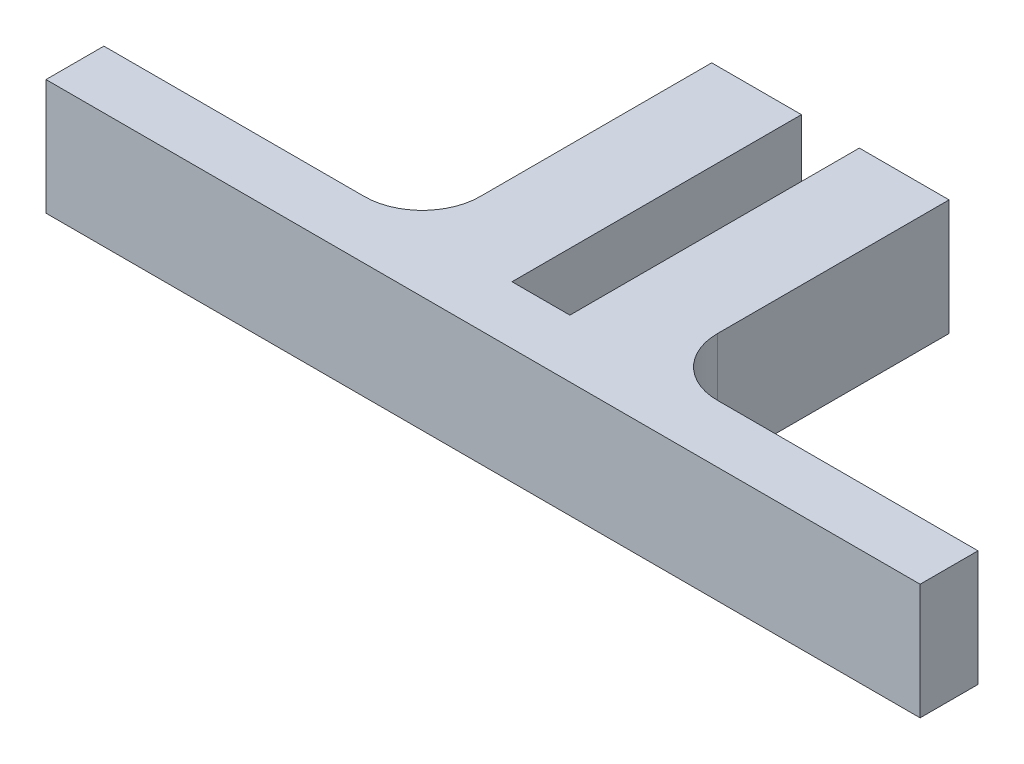
from build123d import *

# Parameters (mm, degrees)
BOSS_EXTRUDE2_DEPTH = 20
SKETCH4_W           = 10
SKETCH4_H           = 20
CUT_EXTRUDE1_DEPTH  = 50


with BuildPart() as part:
    # Sketch1 → Boss-Extrude2 (new body)
    with BuildSketch(Plane(origin=(0, 0, 0), x_dir=(1, 0, 0), z_dir=(0, 1, 0))):
        with BuildLine():
            Line((-80.69665409, 52.02034588), (-35.69665409, 52.02034588))
            ThreePointArc((-35.69665409, 52.02034588), (-28.625586278, 54.949278068), (-25.69665409, 62.02034588))
            Line((-25.69665409, 62.02034588), (-25.69665409, 102.02034588))
            Line((-25.69665409, 102.02034588), (15.30334591, 102.02034588))
            Line((15.30334591, 102.02034588), (15.30334591, 62.02034588))
            ThreePointArc((15.30334591, 62.02034588), (18.232278099, 54.949278068), (25.30334591, 52.02034588))
            Line((25.30334591, 52.02034588), (70.30334591, 52.02034588))
            Line((70.30334591, 52.02034588), (70.30334591, 42.02034588))
            Line((70.30334591, 42.02034588), (-80.69665409, 42.02034588))
            Line((-80.69665409, 42.02034588), (-80.69665409, 52.02034588))
        make_face()
    extrude(amount=BOSS_EXTRUDE2_DEPTH)

    # Sketch4 → Cut-Extrude1 (cut)
    with BuildSketch(Plane(origin=(0, 0, -102.02034588), x_dir=(-1, 0, 0), z_dir=(0, 0, -1))):
        with Locations((5.19665409, 10)):
            Rectangle(SKETCH4_W, SKETCH4_H)
    extrude(amount=-CUT_EXTRUDE1_DEPTH, mode=Mode.SUBTRACT)


solid = part.part
